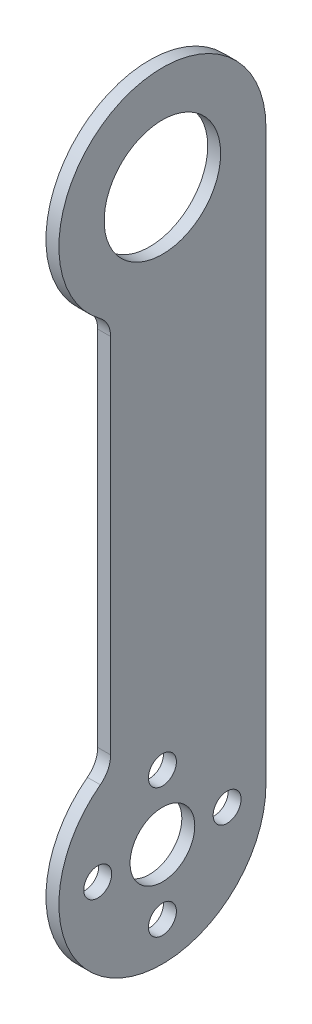
from build123d import *

# Parameters (mm, degrees)
SKETCH1_R           = 7.9375
SKETCH1_R_2         = 14.2875
SKETCH1_R_3         = 3.429
BOSS_EXTRUDE1_DEPTH = 3.175


with BuildPart() as part:
    # Sketch1 → Boss-Extrude1 (new body)
    with BuildSketch(Plane(origin=(0, 0, 0), x_dir=(0, 0, -1), z_dir=(1, 0, 0))):
        with BuildLine():
            Line((25.4, 139.7), (25.4, 0))
            ThreePointArc((25.4, 0), (-11.359225326, -22.718450651), (-15.24, 20.32))
            ThreePointArc((-15.24, 20.32), (-13.370387337, 22.560193669), (-12.7, 25.4))
            Line((-12.7, 25.4), (-12.7, 114.3))
            ThreePointArc((-12.7, 114.3), (-13.370387337, 117.139806331), (-15.24, 119.38))
            ThreePointArc((-15.24, 119.38), (-11.359225326, 162.418450651), (25.4, 139.7))
        make_face()
        Circle(SKETCH1_R, mode=Mode.SUBTRACT)
        with Locations((0, 139.7)):
            Circle(SKETCH1_R_2, mode=Mode.SUBTRACT)
        with Locations((0, 15.875)):
            Circle(SKETCH1_R_3, mode=Mode.SUBTRACT)
        with Locations((15.875, 0)):
            Circle(SKETCH1_R_3, mode=Mode.SUBTRACT)
        with Locations((0, -15.875)):
            Circle(SKETCH1_R_3, mode=Mode.SUBTRACT)
        with Locations((-15.875, 0)):
            Circle(SKETCH1_R_3, mode=Mode.SUBTRACT)
    extrude(amount=BOSS_EXTRUDE1_DEPTH)


solid = part.part
